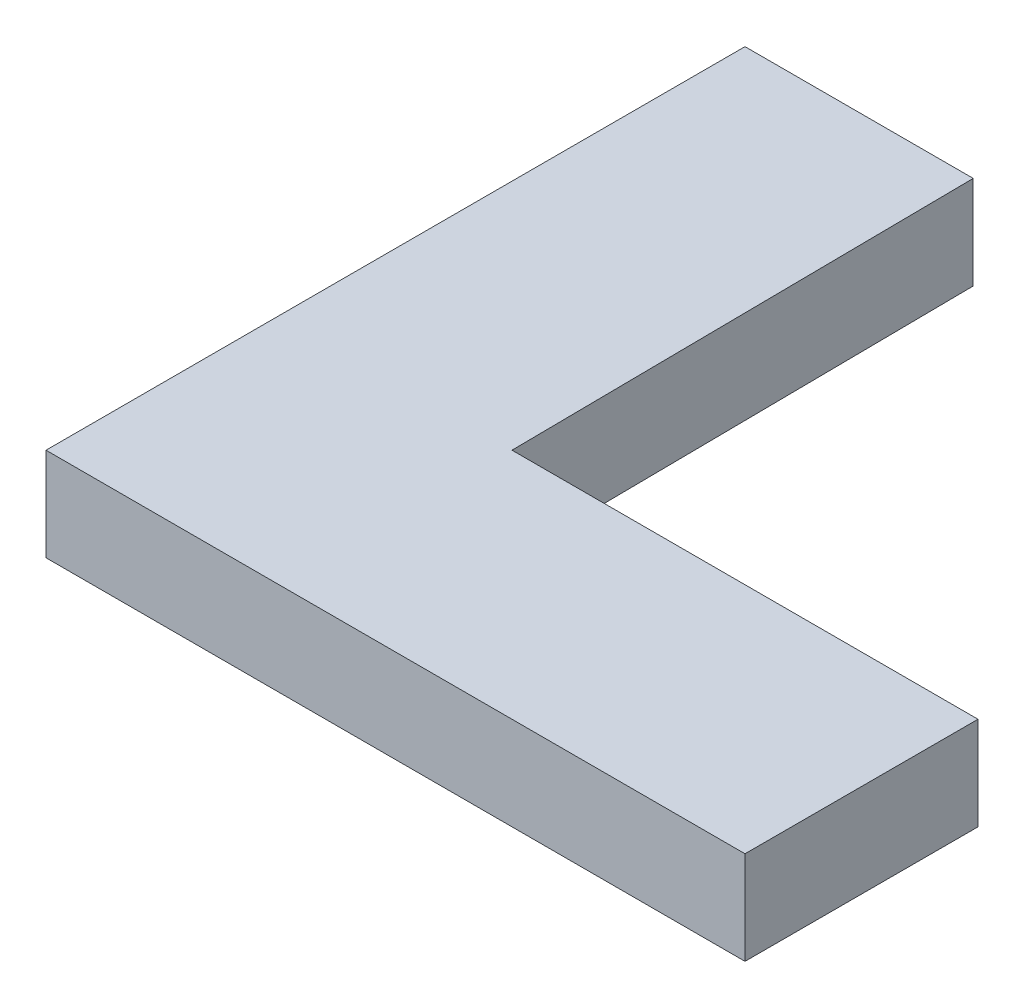
from build123d import *

# Parameters (mm, degrees)
BOSS_EXTRUDE1_DEPTH = 5.08


with BuildPart() as part:
    # Sketch1 → Boss-Extrude1 (new body)
    with BuildSketch(Plane(origin=(0, 0, 0), x_dir=(1, 0, 0), z_dir=(0, 1, 0))):
        Polygon((0, 0), (38.1, 0), (38.1, 12.7), (12.7, 12.7), (12.439585338, 38.1), (0, 38.1), align=None)
    extrude(amount=BOSS_EXTRUDE1_DEPTH)


solid = part.part
